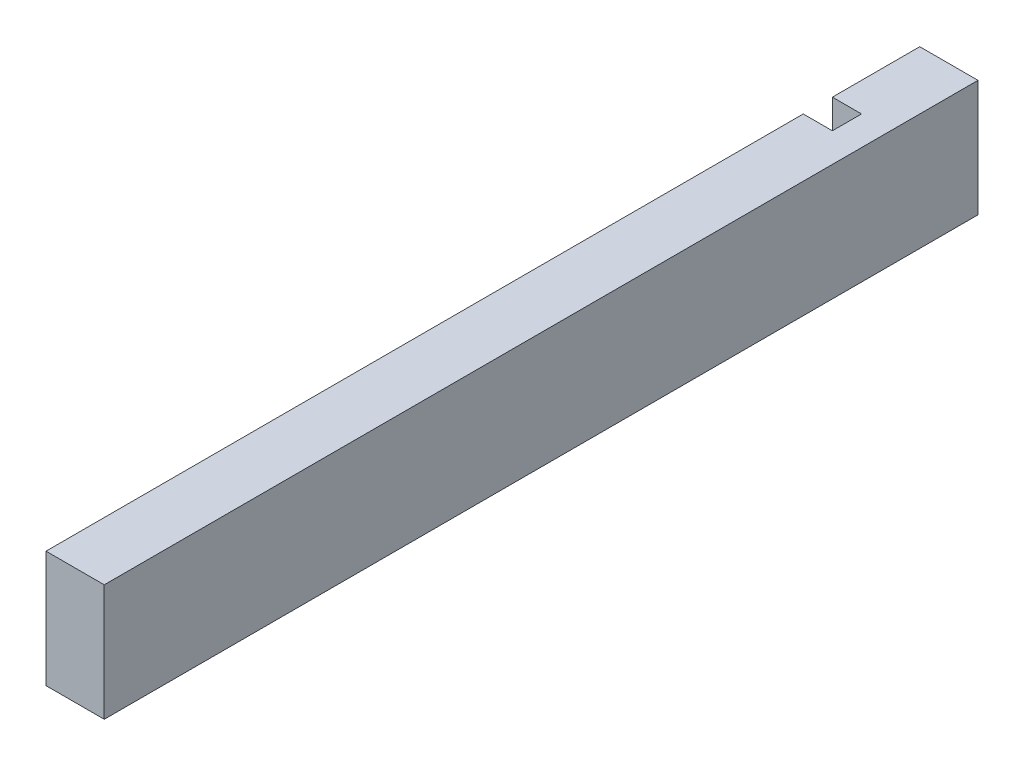
from build123d import *

# Parameters (mm, degrees)
ESQUISSE1_W                  = 20
ESQUISSE1_H                  = 40
BOSS_EXTRU_1_DEPTH           = 300
ENL_V_MAT_EXTRU_1_DEPTH      = 1
ENL_V_MAT_EXTRU_1_DEPTH_BACK = 41


with BuildPart() as part:
    # Esquisse1 → Boss.-Extru.1 (new body)
    with BuildSketch(Plane.XY):
        with Locations((10, 20)):
            Rectangle(ESQUISSE1_W, ESQUISSE1_H)
    extrude(amount=BOSS_EXTRU_1_DEPTH)

    # Esquisse2 → Enlèv. mat.-Extru.1 (cut, two sides)
    with BuildSketch(Plane.XZ) as enl_v_mat_extru_1_sk:
        Polygon((-551.479454827, 30), (0, 30), (10, 30), (10, 40), (0, 40), (-551.479454827, 40), (-1654.438364482, 40), (-1654.438364482, 30), align=None)
    extrude(amount=ENL_V_MAT_EXTRU_1_DEPTH, mode=Mode.SUBTRACT)
    extrude(enl_v_mat_extru_1_sk.sketch, amount=-ENL_V_MAT_EXTRU_1_DEPTH_BACK, mode=Mode.SUBTRACT)


solid = part.part
